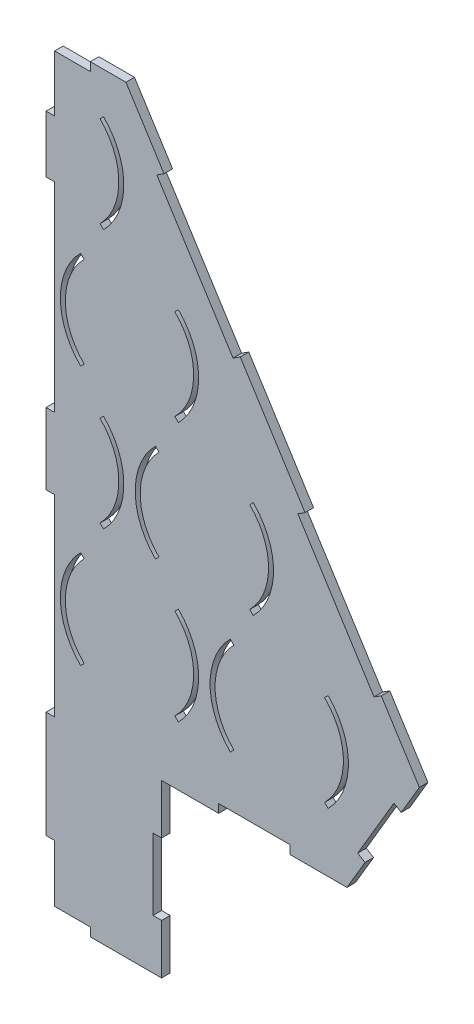
from build123d import *

# Parameters (mm, degrees)
BOSS_EXTRU_1_DEPTH      = 6
ESQUISSE2_W             = 150
ESQUISSE2_H             = 120
BOSS_EXTRU_2_DEPTH      = 6
ESQUISSE3_W             = 6
ESQUISSE3_H             = 50
ESQUISSE3_W_2           = 50
ESQUISSE3_H_2           = 6
ENL_V_MAT_EXTRU_1_DEPTH = 10
ESQUISSE4_W             = 50
ESQUISSE4_H             = 6
ENL_V_MAT_EXTRU_2_DEPTH = 10
ESQUISSE7_W             = 293.706966018
ESQUISSE7_H             = 576.29660199
ENL_V_MAT_EXTRU_4_DEPTH = 10
ESQUISSE8_W             = 6
ESQUISSE8_H             = 40
ESQUISSE8_H_2           = 50
ESQUISSE8_H_3           = 75
BOSS_EXTRU_4_DEPTH      = 6


with BuildPart() as part:
    # Esquisse1 → Boss.-Extru.1 (new body)
    with BuildSketch(Plane.XY):
        Polygon((-50, 335.901139535), (50, 335.901139535), (255.775862069, 10.507079064), (205, -75.642859016), (-205, -75.642859016), (-255.775862069, 10.507079064), align=None)
        with BuildLine():
            Line((-189.319805153, 31.819805153), (-191.794678888, 34.294678888))
            ThreePointArc((-191.794678888, 34.294678888), (-206, 0), (-191.794678888, -34.294678888))
            Line((-191.794678888, -34.294678888), (-189.319805153, -31.819805153))
            ThreePointArc((-189.319805153, -31.819805153), (-202.5, 0), (-189.319805153, 31.819805153))
        make_face(mode=Mode.SUBTRACT)
        with BuildLine():
            Line((-125.680194847, 31.819805153), (-123.205321112, 34.294678888))
            ThreePointArc((-123.205321112, 34.294678888), (-109, 0), (-123.205321112, -34.294678888))
            Line((-123.205321112, -34.294678888), (-125.680194847, -31.819805153))
            ThreePointArc((-125.680194847, -31.819805153), (-112.5, 0), (-125.680194847, 31.819805153))
        make_face(mode=Mode.SUBTRACT)
        with BuildLine():
            Line((-84.319805153, -31.819805153), (-86.794678888, -34.294678888))
            ThreePointArc((-86.794678888, -34.294678888), (-101, 0), (-86.794678888, 34.294678888))
            Line((-86.794678888, 34.294678888), (-84.319805153, 31.819805153))
            ThreePointArc((-84.319805153, 31.819805153), (-97.5, 0), (-84.319805153, -31.819805153))
        make_face(mode=Mode.SUBTRACT)
        with BuildLine():
            Line((-20.680194847, 31.819805153), (-18.205321112, 34.294678888))
            ThreePointArc((-18.205321112, 34.294678888), (-4, 0), (-18.205321112, -34.294678888))
            Line((-18.205321112, -34.294678888), (-20.680194847, -31.819805153))
            ThreePointArc((-20.680194847, -31.819805153), (-7.5, 0), (-20.680194847, 31.819805153))
        make_face(mode=Mode.SUBTRACT)
        with BuildLine():
            Line((20.680194847, -31.819805153), (18.205321112, -34.294678888))
            ThreePointArc((18.205321112, -34.294678888), (4, 0), (18.205321112, 34.294678888))
            Line((18.205321112, 34.294678888), (20.680194847, 31.819805153))
            ThreePointArc((20.680194847, 31.819805153), (7.5, 0), (20.680194847, -31.819805153))
        make_face(mode=Mode.SUBTRACT)
        with BuildLine():
            Line((84.319805153, 31.819805153), (86.794678888, 34.294678888))
            ThreePointArc((86.794678888, 34.294678888), (101, 0), (86.794678888, -34.294678888))
            Line((86.794678888, -34.294678888), (84.319805153, -31.819805153))
            ThreePointArc((84.319805153, -31.819805153), (97.5, 0), (84.319805153, 31.819805153))
        make_face(mode=Mode.SUBTRACT)
        with BuildLine():
            Line((125.680194847, -31.819805153), (123.205321112, -34.294678888))
            ThreePointArc((123.205321112, -34.294678888), (109, 0), (123.205321112, 34.294678888))
            Line((123.205321112, 34.294678888), (125.680194847, 31.819805153))
            ThreePointArc((125.680194847, 31.819805153), (112.5, 0), (125.680194847, -31.819805153))
        make_face(mode=Mode.SUBTRACT)
        with BuildLine():
            Line((189.319805153, 31.819805153), (191.794678888, 34.294678888))
            ThreePointArc((191.794678888, 34.294678888), (206, 0), (191.794678888, -34.294678888))
            Line((191.794678888, -34.294678888), (189.319805153, -31.819805153))
            ThreePointArc((189.319805153, -31.819805153), (202.5, 0), (189.319805153, 31.819805153))
        make_face(mode=Mode.SUBTRACT)
        with BuildLine():
            Line((-139.294678888, 56.63798851), (-136.819805153, 59.112862244))
            ThreePointArc((-136.819805153, 59.112862244), (-150, 90.932667397), (-136.819805153, 122.752472551))
            Line((-136.819805153, 122.752472551), (-139.294678888, 125.227346285))
            ThreePointArc((-139.294678888, 125.227346285), (-153.5, 90.932667397), (-139.294678888, 56.63798851))
        make_face(mode=Mode.SUBTRACT)
        with BuildLine():
            Line((-70.705321112, 56.63798851), (-73.180194847, 59.112862244))
            ThreePointArc((-73.180194847, 59.112862244), (-60, 90.932667397), (-73.180194847, 122.752472551))
            Line((-73.180194847, 122.752472551), (-70.705321112, 125.227346285))
            ThreePointArc((-70.705321112, 125.227346285), (-56.5, 90.932667397), (-70.705321112, 56.63798851))
        make_face(mode=Mode.SUBTRACT)
        with BuildLine():
            Line((-31.819805153, 122.752472551), (-34.294678888, 125.227346285))
            ThreePointArc((-34.294678888, 125.227346285), (-48.5, 90.932667397), (-34.294678888, 56.63798851))
            Line((-34.294678888, 56.63798851), (-31.819805153, 59.112862244))
            ThreePointArc((-31.819805153, 59.112862244), (-45, 90.932667397), (-31.819805153, 122.752472551))
        make_face(mode=Mode.SUBTRACT)
        with BuildLine():
            Line((34.294678888, 56.63798851), (31.819805153, 59.112862244))
            ThreePointArc((31.819805153, 59.112862244), (45, 90.932667397), (31.819805153, 122.752472551))
            Line((31.819805153, 122.752472551), (34.294678888, 125.227346285))
            ThreePointArc((34.294678888, 125.227346285), (48.5, 90.932667397), (34.294678888, 56.63798851))
        make_face(mode=Mode.SUBTRACT)
        with BuildLine():
            Line((73.180194847, 122.752472551), (70.705321112, 125.227346285))
            ThreePointArc((70.705321112, 125.227346285), (56.5, 90.932667397), (70.705321112, 56.63798851))
            Line((70.705321112, 56.63798851), (73.180194847, 59.112862244))
            ThreePointArc((73.180194847, 59.112862244), (60, 90.932667397), (73.180194847, 122.752472551))
        make_face(mode=Mode.SUBTRACT)
        with BuildLine():
            Line((139.294678888, 56.63798851), (136.819805153, 59.112862244))
            ThreePointArc((136.819805153, 59.112862244), (150, 90.932667397), (136.819805153, 122.752472551))
            Line((136.819805153, 122.752472551), (139.294678888, 125.227346285))
            ThreePointArc((139.294678888, 125.227346285), (153.5, 90.932667397), (139.294678888, 56.63798851))
        make_face(mode=Mode.SUBTRACT)
        with BuildLine():
            Line((-84.319805153, 213.685139948), (-86.794678888, 216.160013682))
            ThreePointArc((-86.794678888, 216.160013682), (-101, 181.865334795), (-86.794678888, 147.570655907))
            Line((-86.794678888, 147.570655907), (-84.319805153, 150.045529641))
            ThreePointArc((-84.319805153, 150.045529641), (-97.5, 181.865334795), (-84.319805153, 213.685139948))
        make_face(mode=Mode.SUBTRACT)
        with BuildLine():
            Line((-20.680194847, 213.685139948), (-18.205321112, 216.160013682))
            ThreePointArc((-18.205321112, 216.160013682), (-4, 181.865334795), (-18.205321112, 147.570655907))
            Line((-18.205321112, 147.570655907), (-20.680194847, 150.045529641))
            ThreePointArc((-20.680194847, 150.045529641), (-7.5, 181.865334795), (-20.680194847, 213.685139948))
        make_face(mode=Mode.SUBTRACT)
        with BuildLine():
            Line((20.680194847, 150.045529641), (18.205321112, 147.570655907))
            ThreePointArc((18.205321112, 147.570655907), (4, 181.865334795), (18.205321112, 216.160013682))
            Line((18.205321112, 216.160013682), (20.680194847, 213.685139948))
            ThreePointArc((20.680194847, 213.685139948), (7.5, 181.865334795), (20.680194847, 150.045529641))
        make_face(mode=Mode.SUBTRACT)
        with BuildLine():
            Line((84.319805153, 150.045529641), (86.794678888, 147.570655907))
            ThreePointArc((86.794678888, 147.570655907), (101, 181.865334795), (86.794678888, 216.160013682))
            Line((86.794678888, 216.160013682), (84.319805153, 213.685139948))
            ThreePointArc((84.319805153, 213.685139948), (97.5, 181.865334795), (84.319805153, 150.045529641))
        make_face(mode=Mode.SUBTRACT)
        with BuildLine():
            Line((-31.819805153, 304.617807345), (-34.294678888, 307.09268108))
            ThreePointArc((-34.294678888, 307.09268108), (-48.5, 272.798002192), (-34.294678888, 238.503323305))
            Line((-34.294678888, 238.503323305), (-31.819805153, 240.978197039))
            ThreePointArc((-31.819805153, 240.978197039), (-45, 272.798002192), (-31.819805153, 304.617807345))
        make_face(mode=Mode.SUBTRACT)
        with BuildLine():
            Line((31.819805153, 304.617807345), (34.294678888, 307.09268108))
            ThreePointArc((34.294678888, 307.09268108), (48.5, 272.798002192), (34.294678888, 238.503323305))
            Line((34.294678888, 238.503323305), (31.819805153, 240.978197039))
            ThreePointArc((31.819805153, 240.978197039), (45, 272.798002192), (31.819805153, 304.617807345))
        make_face(mode=Mode.SUBTRACT)
    extrude(amount=BOSS_EXTRU_1_DEPTH)

    # Esquisse2 → Boss.-Extru.2 (add)
    with BuildSketch(Plane.XY.offset(6)):
        with Locations((0, -135.642859016)):
            Rectangle(ESQUISSE2_W, ESQUISSE2_H)
    extrude(amount=-BOSS_EXTRU_2_DEPTH)

    # Esquisse3 → Enlèv. mat.-Extru.1 (cut)
    with BuildSketch(Plane.XY.offset(6)):
        with Locations((-72, -135.642859016)):
            Rectangle(ESQUISSE3_W, ESQUISSE3_H)
        with Locations((0, -192.642859016)):
            Rectangle(ESQUISSE3_W_2, ESQUISSE3_H_2)
        with Locations((72, -135.642859016)):
            Rectangle(ESQUISSE3_W, ESQUISSE3_H)
    extrude(amount=-ENL_V_MAT_EXTRU_1_DEPTH, mode=Mode.SUBTRACT)

    # Esquisse4 → Enlèv. mat.-Extru.2 (cut)
    with BuildSketch(Plane.XY.offset(6)):
        with Locations((-140, -72.642859016)):
            Rectangle(ESQUISSE4_W, ESQUISSE4_H)
        Polygon((-217.693965517, -54.105374496), (-212.524969232, -51.058822772), (-237.912900267, -7.983853732), (-243.081896552, -11.030405456), align=None)
        Polygon((-229.051724138, 52.766047956), (-223.980647871, 49.559151404), (-170.532372009, 134.077089189), (-175.603448276, 137.283985741), align=None)
        Polygon((-71.653061664, 290.43527409), (-76.724137931, 293.642170642), (-130.172413793, 209.124232858), (-125.101337526, 205.917336306), align=None)
        with Locations((0, 332.901139535)):
            Rectangle(ESQUISSE4_W, ESQUISSE4_H)
        with Locations((140, -72.642859016)):
            Rectangle(ESQUISSE4_W, ESQUISSE4_H)
        Polygon((237.912900267, -7.983853732), (243.081896552, -11.030405456), (217.693965517, -54.105374496), (212.524969232, -51.058822772), align=None)
        Polygon((170.532372009, 134.077089189), (175.603448276, 137.283985741), (229.051724138, 52.766047956), (223.980647871, 49.559151404), align=None)
        Polygon((125.101337526, 205.917336306), (130.172413793, 209.124232858), (76.724137931, 293.642170642), (71.653061664, 290.43527409), align=None)
    extrude(amount=-ENL_V_MAT_EXTRU_2_DEPTH, mode=Mode.SUBTRACT)

    # Esquisse7 → Enlèv. mat.-Extru.4 (cut)
    with BuildSketch(Plane.XY.offset(6)):
        with Locations((-146.853483009, 80.947217028)):
            Rectangle(ESQUISSE7_W, ESQUISSE7_H)
    extrude(amount=-ENL_V_MAT_EXTRU_4_DEPTH, mode=Mode.SUBTRACT)

    # Esquisse8 → Boss.-Extru.4 (add)
    with BuildSketch(Plane.XY.offset(6)):
        with Locations((-3, 270.357140984)):
            Rectangle(ESQUISSE8_W, ESQUISSE8_H)
        with Locations((-3, 85.357140984)):
            Rectangle(ESQUISSE8_W, ESQUISSE8_H_2)
        with Locations((-3, -112.142859016)):
            Rectangle(ESQUISSE8_W, ESQUISSE8_H_3)
    extrude(amount=-BOSS_EXTRU_4_DEPTH)


solid = part.part
